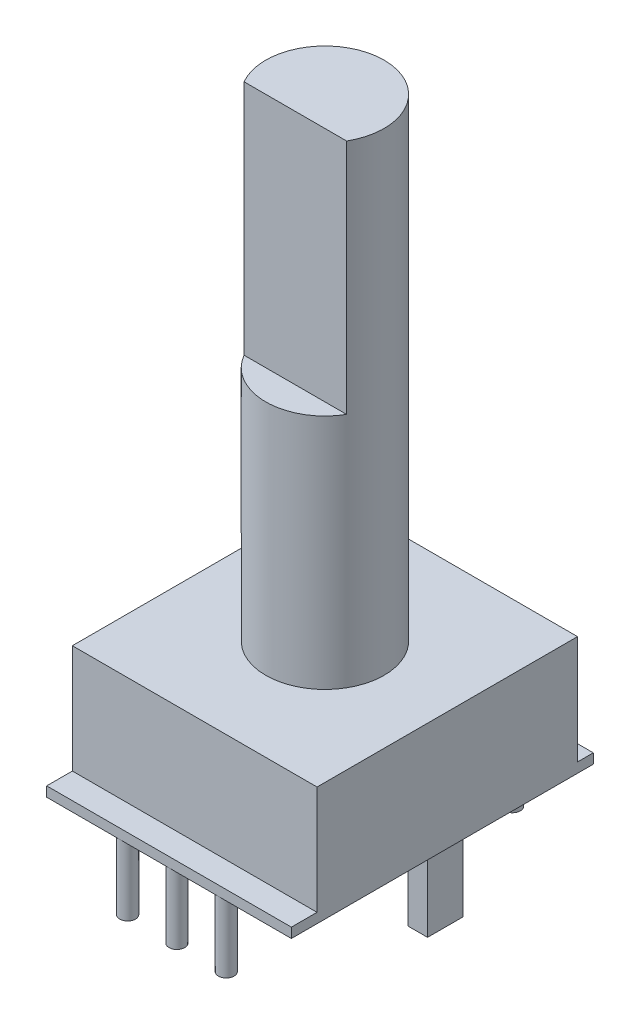
from build123d import *

# Parameters (mm, degrees)
SKETCH1_R             = 0.4
BOSS_EXTRUDE1_DEPTH   = 3.5
BOSS_EXTRUDE1_2_DEPTH = 3.5
BOSS_EXTRUDE1_3_DEPTH = 3.5
BOSS_EXTRUDE1_4_DEPTH = 3.5
BOSS_EXTRUDE1_5_DEPTH = 3.5
SKETCH1_W             = 1
SKETCH1_H             = 1.8
BOSS_EXTRUDE1_6_DEPTH = 3.5
BOSS_EXTRUDE1_7_DEPTH = 3.5
SKETCH2_W             = 12.4
SKETCH2_H             = 13.2
BOSS_EXTRUDE2_DEPTH   = 6
SKETCH3_W             = 12.4
SKETCH3_H             = 15.3
BOSS_EXTRUDE3_DEPTH   = 0.5
SKETCH4_R             = 3
BOSS_EXTRUDE4_DEPTH   = 24
CUT_EXTRUDE1_DEPTH    = 12


with BuildPart() as part:
    # Sketch1 → Boss-Extrude1 (new body)
    with BuildSketch(Plane(origin=(0, 0, 0), x_dir=(1, 0, 0), z_dir=(0, 1, 0))):
        with Locations((-2.5, -7.5)):
            Circle(SKETCH1_R)
    extrude(amount=-BOSS_EXTRUDE1_DEPTH)



with BuildPart() as body_2:
    # Sketch1 → Boss-Extrude1 2 (new body)
    with BuildSketch(Plane(origin=(0, 0, 0), x_dir=(1, 0, 0), z_dir=(0, 1, 0))):
        with Locations((0, -7.5)):
            Circle(SKETCH1_R)
    extrude(amount=-BOSS_EXTRUDE1_2_DEPTH)


with BuildPart() as body_3:
    # Sketch1 → Boss-Extrude1 3 (new body)
    with BuildSketch(Plane(origin=(0, 0, 0), x_dir=(1, 0, 0), z_dir=(0, 1, 0))):
        with Locations((2.5, -7.5)):
            Circle(SKETCH1_R)
    extrude(amount=-BOSS_EXTRUDE1_3_DEPTH)


with BuildPart() as body_4:
    # Sketch1 → Boss-Extrude1 4 (new body)
    with BuildSketch(Plane(origin=(0, 0, 0), x_dir=(1, 0, 0), z_dir=(0, 1, 0))):
        with Locations((2.5, 7)):
            Circle(SKETCH1_R)
    extrude(amount=-BOSS_EXTRUDE1_4_DEPTH)


with BuildPart() as body_5:
    # Sketch1 → Boss-Extrude1 5 (new body)
    with BuildSketch(Plane(origin=(0, 0, 0), x_dir=(1, 0, 0), z_dir=(0, 1, 0))):
        with Locations((-2.5, 7)):
            Circle(SKETCH1_R)
    extrude(amount=-BOSS_EXTRUDE1_5_DEPTH)


with BuildPart() as body_6:
    # Sketch1 → Boss-Extrude1 6 (new body)
    with BuildSketch(Plane(origin=(0, 0, 0), x_dir=(1, 0, 0), z_dir=(0, 1, 0))):
        with Locations((-5.6, 0)):
            Rectangle(SKETCH1_W, SKETCH1_H)
    extrude(amount=-BOSS_EXTRUDE1_6_DEPTH)



with BuildPart() as body_7:
    # Sketch1 → Boss-Extrude1 7 (new body)
    with BuildSketch(Plane(origin=(0, 0, 0), x_dir=(1, 0, 0), z_dir=(0, 1, 0))):
        with Locations((5.6, 0)):
            Rectangle(SKETCH1_W, SKETCH1_H)
    extrude(amount=-BOSS_EXTRUDE1_7_DEPTH)


with BuildPart() as body_6_1:
    add(body_6.part)

    add(body_7.part)  # Boss-Extrude2 merges body 7
    # Sketch2 → Boss-Extrude2 (add)
    with BuildSketch(Plane(origin=(0, 0, 0), x_dir=(1, 0, 0), z_dir=(0, 1, 0))):
        Rectangle(SKETCH2_W, SKETCH2_H)
    extrude(amount=BOSS_EXTRUDE2_DEPTH)


with BuildPart() as part_1:
    add(part.part)

    add(body_2.part)  # Boss-Extrude3 merges body 2

    add(body_3.part)  # Boss-Extrude3 merges body 3

    add(body_4.part)  # Boss-Extrude3 merges body 4

    add(body_5.part)  # Boss-Extrude3 merges body 5

    add(body_6_1.part)  # Boss-Extrude3 merges body 6
    # Sketch3 → Boss-Extrude3 (add)
    with BuildSketch(Plane(origin=(0, 0, 0), x_dir=(1, 0, 0), z_dir=(0, 1, 0))):
        with Locations((0, -0.25)):
            Rectangle(SKETCH3_W, SKETCH3_H)
    extrude(amount=BOSS_EXTRUDE3_DEPTH)

    # Sketch4 → Boss-Extrude4 (add)
    with BuildSketch(Plane(origin=(0, 6, 0), x_dir=(1, 0, 0), z_dir=(0, 1, 0))):
        Circle(SKETCH4_R)
    extrude(amount=BOSS_EXTRUDE4_DEPTH)

    # Sketch5 → Cut-Extrude1 (cut)
    with BuildSketch(Plane(origin=(0, 30, 0), x_dir=(1, 0, 0), z_dir=(0, 1, 0))):
        with BuildLine():
            Line((-2.598076211, -1.5), (2.598076211, -1.5))
            ThreePointArc((2.598076211, -1.5), (0, -3), (-2.598076211, -1.5))
        make_face()
    extrude(amount=-CUT_EXTRUDE1_DEPTH, mode=Mode.SUBTRACT)


solid = part_1.part
